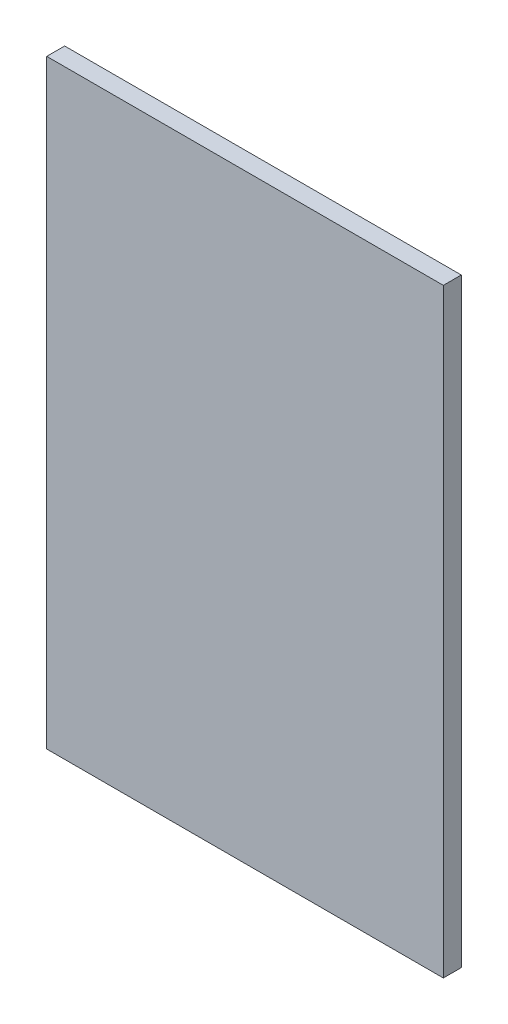
from build123d import *

# Parameters (mm, degrees)
SKETCH1_W           = 398
SKETCH1_H           = 602
BOSS_EXTRUDE1_DEPTH = 18


with BuildPart() as part:
    # Sketch1 → Boss-Extrude1 (new body)
    with BuildSketch(Plane.XY):
        Rectangle(SKETCH1_W, SKETCH1_H)
    extrude(amount=BOSS_EXTRUDE1_DEPTH)


solid = part.part
